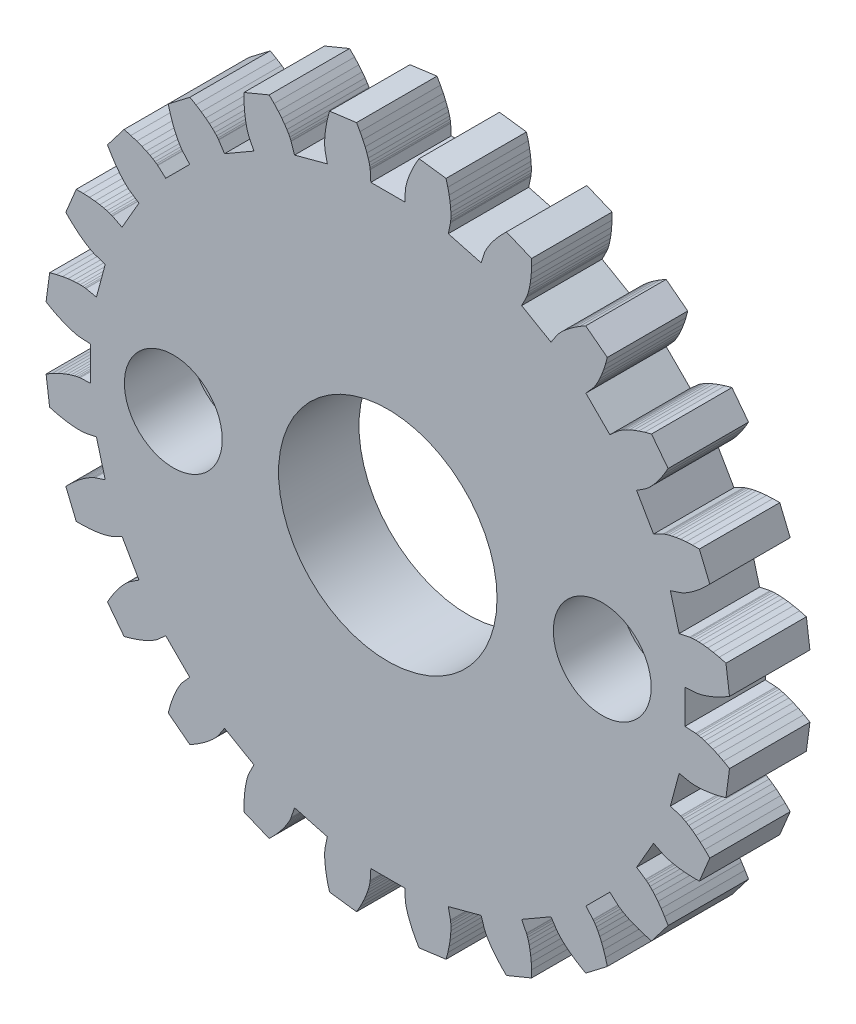
from build123d import *

# Parameters (mm, degrees)
MAIN_GEAR_BODY_DEPTH      = 3
SKETCH1_R                 = 4.075
SKETCH1_R_2               = 1.15
SERVO_CLEARANCE_DEPTH     = 4
SKETCH2_R                 = 1.825
BOLT_HEAD_CLEARANCE_DEPTH = 2.5


with BuildPart() as part:
    # Model → Main Gear Body (new body)
    with BuildSketch(Plane.XY):
        Polygon((11.481280763, -0.655890262), (11.081931867, -0.633076687), (11.081931867, 0.633076687), (11.481280763, 0.655890262), (11.494959484, 0.657119822), (11.535795525, 0.662587053), (11.603342457, 0.674939875), (11.696960474, 0.69678954), (11.81581907, 0.730698092), (11.958900465, 0.779166001), (12.125003794, 0.844620031), (12.312750022, 0.929401369), (12.520587586, 1.035754071), (12.746798737, 1.165813859), (12.614196933, 2.173024562), (12.36203179, 2.240104916), (12.133750014, 2.289041418), (11.930458058, 2.322341602), (11.753073814, 2.342574636), (11.602323381, 2.352358851), (11.478738615, 2.354349128), (11.382655444, 2.351224158), (11.314212973, 2.345673635), (11.273353363, 2.34038543), (11.259822499, 2.338032781), (10.868176499, 2.256709902), (10.540471892, 3.479720146), (10.920308717, 3.605115467), (10.933203113, 3.609843444), (10.971232676, 3.625693529), (11.033280856, 3.655107871), (11.118053808, 3.700443153), (11.224086216, 3.763959167), (11.349747813, 3.847807762), (11.493250558, 3.954022205), (11.652656464, 4.084506989), (11.82588603, 4.24102813), (12.010727273, 4.425203993), (11.621958453, 5.36377495), (11.361023956, 5.363304455), (11.127854994, 5.351489815), (10.922871322, 5.331039494), (10.746294605, 5.304672682), (10.598148527, 5.275106425), (10.478259688, 5.245042794), (10.386259274, 5.21715615), (10.321585504, 5.194080542), (10.28348684, 5.178397283), (10.27102594, 5.172622753), (9.913772864, 4.99270544), (9.280696176, 6.089226427), (9.615135678, 6.30865801), (9.626367017, 6.316562201), (9.658998451, 6.341714983), (9.711319399, 6.386186306), (9.781470148, 6.45191768), (9.867450435, 6.540712645), (9.967128604, 6.654227783), (10.078251291, 6.7939643), (10.198453625, 6.961260207), (10.325269884, 7.157283131), (10.456144594, 7.383023787), (9.837702711, 8.18899294), (9.585781114, 8.121003659), (9.363615046, 8.049243025), (9.170908956, 7.976435853), (9.007173178, 7.905266052), (8.871727365, 7.838364214), (8.76370468, 7.778295462), (8.682056698, 7.727547573), (8.625559041, 7.688519444), (8.592817683, 7.663509918), (8.582275936, 7.654707033), (8.28376199, 7.388456353), (7.388456353, 8.28376199), (7.654707033, 8.582275936), (7.663509918, 8.592817683), (7.688519444, 8.625559041), (7.727547573, 8.682056698), (7.778295462, 8.76370468), (7.838364214, 8.871727365), (7.905266052, 9.007173178), (7.976435853, 9.170908956), (8.049243025, 9.363615046), (8.121003659, 9.585781114), (8.18899294, 9.837702711), (7.383023787, 10.456144594), (7.157283131, 10.325269884), (6.961260207, 10.198453625), (6.7939643, 10.078251291), (6.654227783, 9.967128604), (6.540712645, 9.867450435), (6.45191768, 9.781470148), (6.386186306, 9.711319399), (6.341714983, 9.658998451), (6.316562201, 9.626367017), (6.30865801, 9.615135678), (6.089226427, 9.280696176), (4.99270544, 9.913772864), (5.172622753, 10.27102594), (5.178397283, 10.28348684), (5.194080542, 10.321585504), (5.21715615, 10.386259274), (5.245042794, 10.478259688), (5.275106425, 10.598148527), (5.304672682, 10.746294605), (5.331039494, 10.922871322), (5.351489815, 11.127854994), (5.363304455, 11.361023956), (5.36377495, 11.621958453), (4.425203993, 12.010727273), (4.24102813, 11.82588603), (4.084506989, 11.652656464), (3.954022205, 11.493250558), (3.847807762, 11.349747813), (3.763959167, 11.224086216), (3.700443153, 11.118053808), (3.655107871, 11.033280856), (3.625693529, 10.971232676), (3.609843444, 10.933203113), (3.605115467, 10.920308717), (3.479720146, 10.540471892), (2.256709902, 10.868176499), (2.338032781, 11.259822499), (2.34038543, 11.273353363), (2.345673635, 11.314212973), (2.351224158, 11.382655444), (2.354349128, 11.478738615), (2.352358851, 11.602323381), (2.342574636, 11.753073814), (2.322341602, 11.930458058), (2.289041418, 12.133750014), (2.240104916, 12.36203179), (2.173024562, 12.614196933), (1.165813859, 12.746798737), (1.035754071, 12.520587586), (0.929401369, 12.312750022), (0.844620031, 12.125003794), (0.779166001, 11.958900465), (0.730698092, 11.81581907), (0.69678954, 11.696960474), (0.674939875, 11.603342457), (0.662587053, 11.535795525), (0.657119822, 11.494959484), (0.655890262, 11.481280763), (0.633076687, 11.081931867), (-0.633076687, 11.081931867), (-0.655890262, 11.481280763), (-0.657119822, 11.494959484), (-0.662587053, 11.535795525), (-0.674939875, 11.603342457), (-0.69678954, 11.696960474), (-0.730698092, 11.81581907), (-0.779166001, 11.958900465), (-0.844620031, 12.125003794), (-0.929401369, 12.312750022), (-1.035754071, 12.520587586), (-1.165813859, 12.746798737), (-2.173024562, 12.614196933), (-2.240104916, 12.36203179), (-2.289041418, 12.133750014), (-2.322341602, 11.930458058), (-2.342574636, 11.753073814), (-2.352358851, 11.602323381), (-2.354349128, 11.478738615), (-2.351224158, 11.382655444), (-2.345673635, 11.314212973), (-2.34038543, 11.273353363), (-2.338032781, 11.259822499), (-2.256709902, 10.868176499), (-3.479720146, 10.540471892), (-3.605115467, 10.920308717), (-3.609843444, 10.933203113), (-3.625693529, 10.971232676), (-3.655107871, 11.033280856), (-3.700443153, 11.118053808), (-3.763959167, 11.224086216), (-3.847807762, 11.349747813), (-3.954022205, 11.493250558), (-4.084506989, 11.652656464), (-4.24102813, 11.82588603), (-4.425203993, 12.010727273), (-5.36377495, 11.621958453), (-5.363304455, 11.361023956), (-5.351489815, 11.127854994), (-5.331039494, 10.922871322), (-5.304672682, 10.746294605), (-5.275106425, 10.598148527), (-5.245042794, 10.478259688), (-5.21715615, 10.386259274), (-5.194080542, 10.321585504), (-5.178397283, 10.28348684), (-5.172622753, 10.27102594), (-4.99270544, 9.913772864), (-6.089226427, 9.280696176), (-6.30865801, 9.615135678), (-6.316562201, 9.626367017), (-6.341714983, 9.658998451), (-6.386186306, 9.711319399), (-6.45191768, 9.781470148), (-6.540712645, 9.867450435), (-6.654227783, 9.967128604), (-6.7939643, 10.078251291), (-6.961260207, 10.198453625), (-7.157283131, 10.325269884), (-7.383023787, 10.456144594), (-8.18899294, 9.837702711), (-8.121003659, 9.585781114), (-8.049243025, 9.363615046), (-7.976435853, 9.170908956), (-7.905266052, 9.007173178), (-7.838364214, 8.871727365), (-7.778295462, 8.76370468), (-7.727547573, 8.682056698), (-7.688519444, 8.625559041), (-7.663509918, 8.592817683), (-7.654707033, 8.582275936), (-7.388456353, 8.28376199), (-8.28376199, 7.388456353), (-8.582275936, 7.654707033), (-8.592817683, 7.663509918), (-8.625559041, 7.688519444), (-8.682056698, 7.727547573), (-8.76370468, 7.778295462), (-8.871727365, 7.838364214), (-9.007173178, 7.905266052), (-9.170908956, 7.976435853), (-9.363615046, 8.049243025), (-9.585781114, 8.121003659), (-9.837702711, 8.18899294), (-10.456144594, 7.383023787), (-10.325269884, 7.157283131), (-10.198453625, 6.961260207), (-10.078251291, 6.7939643), (-9.967128604, 6.654227783), (-9.867450435, 6.540712645), (-9.781470148, 6.45191768), (-9.711319399, 6.386186306), (-9.658998451, 6.341714983), (-9.626367017, 6.316562201), (-9.615135678, 6.30865801), (-9.280696176, 6.089226427), (-9.913772864, 4.99270544), (-10.27102594, 5.172622753), (-10.28348684, 5.178397283), (-10.321585504, 5.194080542), (-10.386259274, 5.21715615), (-10.478259688, 5.245042794), (-10.598148527, 5.275106425), (-10.746294605, 5.304672682), (-10.922871322, 5.331039494), (-11.127854994, 5.351489815), (-11.361023956, 5.363304455), (-11.621958453, 5.36377495), (-12.010727273, 4.425203993), (-11.82588603, 4.24102813), (-11.652656464, 4.084506989), (-11.493250558, 3.954022205), (-11.349747813, 3.847807762), (-11.224086216, 3.763959167), (-11.118053808, 3.700443153), (-11.033280856, 3.655107871), (-10.971232676, 3.625693529), (-10.933203113, 3.609843444), (-10.920308717, 3.605115467), (-10.540471892, 3.479720146), (-10.868176499, 2.256709902), (-11.259822499, 2.338032781), (-11.273353363, 2.34038543), (-11.314212973, 2.345673635), (-11.382655444, 2.351224158), (-11.478738615, 2.354349128), (-11.602323381, 2.352358851), (-11.753073814, 2.342574636), (-11.930458058, 2.322341602), (-12.133750014, 2.289041418), (-12.36203179, 2.240104916), (-12.614196933, 2.173024562), (-12.746798737, 1.165813859), (-12.520587586, 1.035754071), (-12.312750022, 0.929401369), (-12.125003794, 0.844620031), (-11.958900465, 0.779166001), (-11.81581907, 0.730698092), (-11.696960474, 0.69678954), (-11.603342457, 0.674939875), (-11.535795525, 0.662587053), (-11.494959484, 0.657119822), (-11.481280763, 0.655890262), (-11.081931867, 0.633076687), (-11.081931867, -0.633076687), (-11.481280763, -0.655890262), (-11.494959484, -0.657119822), (-11.535795525, -0.662587053), (-11.603342457, -0.674939875), (-11.696960474, -0.69678954), (-11.81581907, -0.730698092), (-11.958900465, -0.779166001), (-12.125003794, -0.844620031), (-12.312750022, -0.929401369), (-12.520587586, -1.035754071), (-12.746798737, -1.165813859), (-12.614196933, -2.173024562), (-12.36203179, -2.240104916), (-12.133750014, -2.289041418), (-11.930458058, -2.322341602), (-11.753073814, -2.342574636), (-11.602323381, -2.352358851), (-11.478738615, -2.354349128), (-11.382655444, -2.351224158), (-11.314212973, -2.345673635), (-11.273353363, -2.34038543), (-11.259822499, -2.338032781), (-10.868176499, -2.256709902), (-10.540471892, -3.479720146), (-10.920308717, -3.605115467), (-10.933203113, -3.609843444), (-10.971232676, -3.625693529), (-11.033280856, -3.655107871), (-11.118053808, -3.700443153), (-11.224086216, -3.763959167), (-11.349747813, -3.847807762), (-11.493250558, -3.954022205), (-11.652656464, -4.084506989), (-11.82588603, -4.24102813), (-12.010727273, -4.425203993), (-11.621958453, -5.36377495), (-11.361023956, -5.363304455), (-11.127854994, -5.351489815), (-10.922871322, -5.331039494), (-10.746294605, -5.304672682), (-10.598148527, -5.275106425), (-10.478259688, -5.245042794), (-10.386259274, -5.21715615), (-10.321585504, -5.194080542), (-10.28348684, -5.178397283), (-10.27102594, -5.172622753), (-9.913772864, -4.99270544), (-9.280696176, -6.089226427), (-9.615135678, -6.30865801), (-9.626367017, -6.316562201), (-9.658998451, -6.341714983), (-9.711319399, -6.386186306), (-9.781470148, -6.45191768), (-9.867450435, -6.540712645), (-9.967128604, -6.654227783), (-10.078251291, -6.7939643), (-10.198453625, -6.961260207), (-10.325269884, -7.157283131), (-10.456144594, -7.383023787), (-9.837702711, -8.18899294), (-9.585781114, -8.121003659), (-9.363615046, -8.049243025), (-9.170908956, -7.976435853), (-9.007173178, -7.905266052), (-8.871727365, -7.838364214), (-8.76370468, -7.778295462), (-8.682056698, -7.727547573), (-8.625559041, -7.688519444), (-8.592817683, -7.663509918), (-8.582275936, -7.654707033), (-8.28376199, -7.388456353), (-7.388456353, -8.28376199), (-7.654707033, -8.582275936), (-7.663509918, -8.592817683), (-7.688519444, -8.625559041), (-7.727547573, -8.682056698), (-7.778295462, -8.76370468), (-7.838364214, -8.871727365), (-7.905266052, -9.007173178), (-7.976435853, -9.170908956), (-8.049243025, -9.363615046), (-8.121003659, -9.585781114), (-8.18899294, -9.837702711), (-7.383023787, -10.456144594), (-7.157283131, -10.325269884), (-6.961260207, -10.198453625), (-6.7939643, -10.078251291), (-6.654227783, -9.967128604), (-6.540712645, -9.867450435), (-6.45191768, -9.781470148), (-6.386186306, -9.711319399), (-6.341714983, -9.658998451), (-6.316562201, -9.626367017), (-6.30865801, -9.615135678), (-6.089226427, -9.280696176), (-4.99270544, -9.913772864), (-5.172622753, -10.27102594), (-5.178397283, -10.28348684), (-5.194080542, -10.321585504), (-5.21715615, -10.386259274), (-5.245042794, -10.478259688), (-5.275106425, -10.598148527), (-5.304672682, -10.746294605), (-5.331039494, -10.922871322), (-5.351489815, -11.127854994), (-5.363304455, -11.361023956), (-5.36377495, -11.621958453), (-4.425203993, -12.010727273), (-4.24102813, -11.82588603), (-4.084506989, -11.652656464), (-3.954022205, -11.493250558), (-3.847807762, -11.349747813), (-3.763959167, -11.224086216), (-3.700443153, -11.118053808), (-3.655107871, -11.033280856), (-3.625693529, -10.971232676), (-3.609843444, -10.933203113), (-3.605115467, -10.920308717), (-3.479720146, -10.540471892), (-2.256709902, -10.868176499), (-2.338032781, -11.259822499), (-2.34038543, -11.273353363), (-2.345673635, -11.314212973), (-2.351224158, -11.382655444), (-2.354349128, -11.478738615), (-2.352358851, -11.602323381), (-2.342574636, -11.753073814), (-2.322341602, -11.930458058), (-2.289041418, -12.133750014), (-2.240104916, -12.36203179), (-2.173024562, -12.614196933), (-1.165813859, -12.746798737), (-1.035754071, -12.520587586), (-0.929401369, -12.312750022), (-0.844620031, -12.125003794), (-0.779166001, -11.958900465), (-0.730698092, -11.81581907), (-0.69678954, -11.696960474), (-0.674939875, -11.603342457), (-0.662587053, -11.535795525), (-0.657119822, -11.494959484), (-0.655890262, -11.481280763), (-0.633076687, -11.081931867), (0.633076687, -11.081931867), (0.655890262, -11.481280763), (0.657119822, -11.494959484), (0.662587053, -11.535795525), (0.674939875, -11.603342457), (0.69678954, -11.696960474), (0.730698092, -11.81581907), (0.779166001, -11.958900465), (0.844620031, -12.125003794), (0.929401369, -12.312750022), (1.035754071, -12.520587586), (1.165813859, -12.746798737), (2.173024562, -12.614196933), (2.240104916, -12.36203179), (2.289041418, -12.133750014), (2.322341602, -11.930458058), (2.342574636, -11.753073814), (2.352358851, -11.602323381), (2.354349128, -11.478738615), (2.351224158, -11.382655444), (2.345673635, -11.314212973), (2.34038543, -11.273353363), (2.338032781, -11.259822499), (2.256709902, -10.868176499), (3.479720146, -10.540471892), (3.605115467, -10.920308717), (3.609843444, -10.933203113), (3.625693529, -10.971232676), (3.655107871, -11.033280856), (3.700443153, -11.118053808), (3.763959167, -11.224086216), (3.847807762, -11.349747813), (3.954022205, -11.493250558), (4.084506989, -11.652656464), (4.24102813, -11.82588603), (4.425203993, -12.010727273), (5.36377495, -11.621958453), (5.363304455, -11.361023956), (5.351489815, -11.127854994), (5.331039494, -10.922871322), (5.304672682, -10.746294605), (5.275106425, -10.598148527), (5.245042794, -10.478259688), (5.21715615, -10.386259274), (5.194080542, -10.321585504), (5.178397283, -10.28348684), (5.172622753, -10.27102594), (4.99270544, -9.913772864), (6.089226427, -9.280696176), (6.30865801, -9.615135678), (6.316562201, -9.626367017), (6.341714983, -9.658998451), (6.386186306, -9.711319399), (6.45191768, -9.781470148), (6.540712645, -9.867450435), (6.654227783, -9.967128604), (6.7939643, -10.078251291), (6.961260207, -10.198453625), (7.157283131, -10.325269884), (7.383023787, -10.456144594), (8.18899294, -9.837702711), (8.121003659, -9.585781114), (8.049243025, -9.363615046), (7.976435853, -9.170908956), (7.905266052, -9.007173178), (7.838364214, -8.871727365), (7.778295462, -8.76370468), (7.727547573, -8.682056698), (7.688519444, -8.625559041), (7.663509918, -8.592817683), (7.654707033, -8.582275936), (7.388456353, -8.28376199), (8.28376199, -7.388456353), (8.582275936, -7.654707033), (8.592817683, -7.663509918), (8.625559041, -7.688519444), (8.682056698, -7.727547573), (8.76370468, -7.778295462), (8.871727365, -7.838364214), (9.007173178, -7.905266052), (9.170908956, -7.976435853), (9.363615046, -8.049243025), (9.585781114, -8.121003659), (9.837702711, -8.18899294), (10.456144594, -7.383023787), (10.325269884, -7.157283131), (10.198453625, -6.961260207), (10.078251291, -6.7939643), (9.967128604, -6.654227783), (9.867450435, -6.540712645), (9.781470148, -6.45191768), (9.711319399, -6.386186306), (9.658998451, -6.341714983), (9.626367017, -6.316562201), (9.615135678, -6.30865801), (9.280696176, -6.089226427), (9.913772864, -4.99270544), (10.27102594, -5.172622753), (10.28348684, -5.178397283), (10.321585504, -5.194080542), (10.386259274, -5.21715615), (10.478259688, -5.245042794), (10.598148527, -5.275106425), (10.746294605, -5.304672682), (10.922871322, -5.331039494), (11.127854994, -5.351489815), (11.361023956, -5.363304455), (11.621958453, -5.36377495), (12.010727273, -4.425203993), (11.82588603, -4.24102813), (11.652656464, -4.084506989), (11.493250558, -3.954022205), (11.349747813, -3.847807762), (11.224086216, -3.763959167), (11.118053808, -3.700443153), (11.033280856, -3.655107871), (10.971232676, -3.625693529), (10.933203113, -3.609843444), (10.920308717, -3.605115467), (10.540471892, -3.479720146), (10.868176499, -2.256709902), (11.259822499, -2.338032781), (11.273353363, -2.34038543), (11.314212973, -2.345673635), (11.382655444, -2.351224158), (11.478738615, -2.354349128), (11.602323381, -2.352358851), (11.753073814, -2.342574636), (11.930458058, -2.322341602), (12.133750014, -2.289041418), (12.36203179, -2.240104916), (12.614196933, -2.173024562), (12.746798737, -1.165813859), (12.520587586, -1.035754071), (12.312750022, -0.929401369), (12.125003794, -0.844620031), (11.958900465, -0.779166001), (11.81581907, -0.730698092), (11.696960474, -0.69678954), (11.603342457, -0.674939875), (11.535795525, -0.662587053), (11.494959484, -0.657119822), align=None)
    extrude(amount=MAIN_GEAR_BODY_DEPTH)

    # Sketch1 → Servo Clearance (cut, through all)
    with BuildSketch(Plane.XY.offset(3)):
        Circle(SKETCH1_R)
        with Locations((-8, 0)):
            Circle(SKETCH1_R_2)
        with Locations((8, 0)):
            Circle(SKETCH1_R_2)
    extrude(amount=-SERVO_CLEARANCE_DEPTH, mode=Mode.SUBTRACT)

    # Sketch2 → Bolt Head Clearance (cut)
    with BuildSketch(Plane.XY.offset(3)):
        with Locations((8, 0)):
            Circle(SKETCH2_R)
        with Locations((-8, 0)):
            Circle(SKETCH2_R)
    extrude(amount=-BOLT_HEAD_CLEARANCE_DEPTH, mode=Mode.SUBTRACT)


solid = part.part
